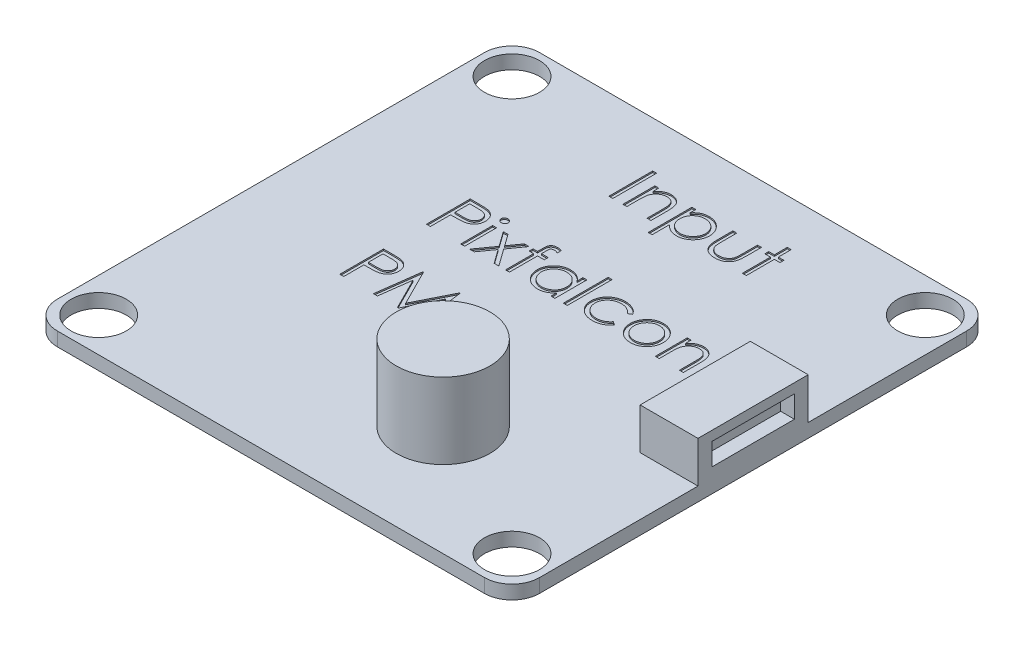
from build123d import *

# Parameters (mm, degrees)
SKETCH1_R           = 2
BOSS_EXTRUDE1_DEPTH = 1
SKETCH2_W           = 4.2
SKETCH2_H           = 8
BOSS_EXTRUDE2_DEPTH = 3
SKETCH3_W           = 6
SKETCH3_H           = 1.6
CUT_EXTRUDE1_DEPTH  = 1
SKETCH4_R           = 3.4
BOSS_EXTRUDE3_DEPTH = 5.5
SKETCH5_W           = 0.284935898
SKETCH5_H           = 2.320192307
SKETCH5_W_2         = 0.284935897
SKETCH5_H_2         = 3.256410256
SKETCH5_H_3         = 3.175
CUT_EXTRUDE2_DEPTH  = 0.1


with BuildPart() as part:
    # Sketch1 → Boss-Extrude1 (new body)
    with BuildSketch(Plane(origin=(0, 0, 0), x_dir=(1, 0, 0), z_dir=(0, 1, 0))):
        with BuildLine():
            Line((-15.5, 17.5), (15.5, 17.5))
            ThreePointArc((15.5, 17.5), (16.914213562, 16.914213562), (17.5, 15.5))
            Line((17.5, 15.5), (17.5, -15.5))
            ThreePointArc((17.5, -15.5), (16.914213562, -16.914213562), (15.5, -17.5))
            Line((15.5, -17.5), (-15.5, -17.5))
            ThreePointArc((-15.5, -17.5), (-16.914213562, -16.914213562), (-17.5, -15.5))
            Line((-17.5, -15.5), (-17.5, 15.5))
            ThreePointArc((-17.5, 15.5), (-16.914213562, 16.914213562), (-15.5, 17.5))
        make_face()
        with Locations((15, 15)):
            Circle(SKETCH1_R, mode=Mode.SUBTRACT)
        with Locations((15, -15)):
            Circle(SKETCH1_R, mode=Mode.SUBTRACT)
        with Locations((-15, -15)):
            Circle(SKETCH1_R, mode=Mode.SUBTRACT)
        with Locations((-15, 15)):
            Circle(SKETCH1_R, mode=Mode.SUBTRACT)
    extrude(amount=BOSS_EXTRUDE1_DEPTH)

    # Sketch2 → Boss-Extrude2 (add)
    with BuildSketch(Plane(origin=(0, 1, 0), x_dir=(1, 0, 0), z_dir=(0, 1, 0))):
        with Locations((15.4, 0)):
            Rectangle(SKETCH2_W, SKETCH2_H)
    extrude(amount=BOSS_EXTRUDE2_DEPTH)

    # Sketch3 → Cut-Extrude1 (cut)
    with BuildSketch(Plane(origin=(17.5, 0, 0), x_dir=(0, 0, -1), z_dir=(1, 0, 0))):
        with Locations((0, 2.5)):
            Rectangle(SKETCH3_W, SKETCH3_H)
    extrude(amount=-CUT_EXTRUDE1_DEPTH, mode=Mode.SUBTRACT)

    # Sketch4 → Boss-Extrude3 (add)
    with BuildSketch(Plane(origin=(0, 1, 0), x_dir=(1, 0, 0), z_dir=(0, 1, 0))):
        with Locations((4.5, -9.5)):
            Circle(SKETCH4_R)
    extrude(amount=BOSS_EXTRUDE3_DEPTH)

    # Sketch5 → Cut-Extrude2 (cut)
    with BuildSketch(Plane(origin=(0, 1, 0), x_dir=(1, 0, 0), z_dir=(0, 1, 0))):
        with BuildLine():
            Line((-8.813380042, 5.781823516), (-8.190718784, 5.781823516))
            add(Edge.make_bspline(
                [(-8.190718784, 5.781823516), (-8.147891748, 5.781776438), (-8.065833244, 5.781686236), (-7.948163158, 5.778951431), (-7.841292901, 5.775298646), (-7.745452913, 5.770235072), (-7.66034831, 5.764251022), (-7.586364188, 5.7558581), (-7.522919019, 5.747094832), (-7.484903883, 5.738185414), (-7.467566741, 5.734122194)],
                knots=[0, 0, 0, 0, 0.000128477, 0.000246168, 0.000353087, 0.00044926, 0.000534089, 0.000608961, 0.000672646, 0.000726041, 0.000726041, 0.000726041, 0.000726041], degree=3))
            add(Edge.make_bspline(
                [(-7.467566741, 5.734122194), (-7.445619749, 5.728115139), (-7.40224292, 5.716242579), (-7.339739831, 5.692462987), (-7.280273128, 5.664267023), (-7.223638786, 5.632132449), (-7.170532754, 5.594680544), (-7.120162702, 5.553429477), (-7.072973149, 5.507426839), (-7.029229457, 5.457188597), (-6.989056819, 5.403558121), (-6.95446775, 5.345734812), (-6.925505194, 5.284691987), (-6.900664655, 5.220472104), (-6.882786271, 5.152535882), (-6.869318012, 5.081355365), (-6.860769436, 5.006938182), (-6.859950683, 4.956083873), (-6.859533888, 4.930195912)],
                knots=[0, 0, 0, 0, 6.8232e-05, 0.000134856, 0.000200292, 0.000265532, 0.000329934, 0.000395001, 0.000460668, 0.00052738, 0.000594672, 0.000661426, 0.000729131, 0.00079717, 0.00086768, 0.00093953, 0.001014402, 0.001092038, 0.001092038, 0.001092038, 0.001092038], degree=3))
            add(Edge.make_bspline(
                [(-6.859533888, 4.930195912), (-6.859916181, 4.904090357), (-6.860664162, 4.853013076), (-6.869641506, 4.77828919), (-6.881733894, 4.706880364), (-6.900327649, 4.638944934), (-6.924680509, 4.574886342), (-6.9532483, 4.513725653), (-6.987704789, 4.45650338), (-7.027296884, 4.40301178), (-7.071340116, 4.353200645), (-7.119648139, 4.307430939), (-7.172025925, 4.265970575), (-7.228307017, 4.228726606), (-7.289040094, 4.196562695), (-7.353304048, 4.167754283), (-7.421657458, 4.143559821), (-7.468958167, 4.130832551), (-7.493007446, 4.124361577)],
                knots=[0, 0, 0, 0, 7.8272e-05, 0.000153144, 0.000225504, 0.0002954, 0.000364034, 0.000430891, 0.000497646, 0.000564048, 0.000630282, 0.000696867, 0.000763418, 0.000830451, 0.000899029, 0.000969354, 0.001041572, 0.001116269, 0.001116269, 0.001116269, 0.001116269], degree=3))
            add(Edge.make_bspline(
                [(-7.493007446, 4.124361577), (-7.51289867, 4.120131587), (-7.556491445, 4.110861318), (-7.6282852, 4.100512218), (-7.711874229, 4.091678823), (-7.80714444, 4.085055648), (-7.914010318, 4.079385671), (-8.032529673, 4.0748789), (-8.162935157, 4.072402532), (-8.2538955, 4.072274813), (-8.301385851, 4.072208131)],
                knots=[0, 0, 0, 0, 6.0995e-05, 0.000133673, 0.000217466, 0.000313125, 0.000420129, 0.000538512, 0.000668921, 0.00081139, 0.00081139, 0.00081139, 0.00081139], degree=3))
            Line((-8.301385851, 4.072208131), (-8.528444145, 4.072208131))
            Line((-8.528444145, 4.072208131), (-8.528444145, 2.606823516))
            Line((-8.528444145, 2.606823516), (-8.813380042, 2.606823516))
            Line((-8.813380042, 2.606823516), (-8.813380042, 5.781823516))
        make_face()
        with BuildLine():
            Line((-8.528444145, 5.45618249), (-8.528444145, 4.397849157))
            Line((-8.528444145, 4.397849157), (-7.972564738, 4.390852963))
            add(Edge.make_bspline(
                [(-7.972564738, 4.390852963), (-7.945423091, 4.390838935), (-7.893026701, 4.390811855), (-7.817338127, 4.394427022), (-7.747116845, 4.398600362), (-7.682578551, 4.404710807), (-7.623694154, 4.413347948), (-7.570365467, 4.422067167), (-7.523006003, 4.434681318), (-7.467580298, 4.451665816), (-7.405818976, 4.48063326), (-7.338629129, 4.522679232), (-7.281687239, 4.576273874), (-7.232412785, 4.636533407), (-7.193309595, 4.703570475), (-7.164683802, 4.775297296), (-7.147864324, 4.850978274), (-7.145608991, 4.902765371), (-7.144469786, 4.928923876)],
                knots=[0, 0, 0, 0, 8.1413e-05, 0.000157166, 0.000227269, 0.000292454, 0.000351549, 0.000405819, 0.000454411, 0.000498462, 0.000579576, 0.00065826, 0.000735229, 0.000813005, 0.000891109, 0.000967051, 0.001043901, 0.00112234, 0.00112234, 0.00112234, 0.00112234], degree=3))
            add(Edge.make_bspline(
                [(-7.144469786, 4.928923876), (-7.145615186, 4.954449528), (-7.147892101, 5.005191364), (-7.164815634, 5.079557811), (-7.19325394, 5.150528771), (-7.23267528, 5.216725784), (-7.280519019, 5.276768485), (-7.33612628, 5.328926593), (-7.399366167, 5.370856281), (-7.458192777, 5.397919329), (-7.510445281, 5.414443186), (-7.555831417, 5.426004577), (-7.607076528, 5.435235306), (-7.6641973, 5.442709712), (-7.726750999, 5.449108209), (-7.795275042, 5.453449774), (-7.869509847, 5.455991095), (-7.92104515, 5.456117147), (-7.94776005, 5.45618249)],
                knots=[0, 0, 0, 0, 7.6536e-05, 0.000152145, 0.000227496, 0.000305051, 0.000382429, 0.000457133, 0.000532809, 0.00060908, 0.000650514, 0.0006971, 0.000749494, 0.000806611, 0.000869897, 0.000938097, 0.001012554, 0.001092695, 0.001092695, 0.001092695, 0.001092695], degree=3))
            Line((-7.94776005, 5.45618249), (-8.528444145, 5.45618249))
        make_face(mode=Mode.SUBTRACT)
        with BuildLine():
            add(Edge.make_bspline(
                [(-6.189171308, 5.9039389), (-6.1714899, 5.903118705), (-6.136866308, 5.901512605), (-6.086798129, 5.887758979), (-6.04120784, 5.864445693), (-6.000769468, 5.833167697), (-5.966069542, 5.796383559), (-5.941775612, 5.753511109), (-5.92616151, 5.70719363), (-5.924275963, 5.674885656), (-5.92331594, 5.658436096)],
                knots=[0, 0, 0, 0, 5.2977e-05, 0.000103739, 0.000154369, 0.000205635, 0.000256504, 0.000304942, 0.000352409, 0.000401646, 0.000401646, 0.000401646, 0.000401646], degree=3))
            add(Edge.make_bspline(
                [(-5.92331594, 5.658436096), (-5.924297613, 5.642413546), (-5.926238266, 5.610738862), (-5.941763551, 5.565224355), (-5.966276581, 5.522947612), (-6.000747217, 5.486234896), (-6.041213736, 5.454974191), (-6.086796563, 5.431656321), (-6.13686672, 5.41790391), (-6.171490039, 5.416297643), (-6.189171308, 5.415477362)],
                knots=[0, 0, 0, 0, 4.7972e-05, 9.4835e-05, 0.000142722, 0.000193592, 0.000244857, 0.000295488, 0.00034625, 0.000399227, 0.000399227, 0.000399227, 0.000399227], degree=3))
            add(Edge.make_bspline(
                [(-6.189171308, 5.415477362), (-6.206650386, 5.416266322), (-6.240671128, 5.417801931), (-6.289989621, 5.431926161), (-6.335191179, 5.45498217), (-6.375708418, 5.48603021), (-6.409481522, 5.523173081), (-6.434063574, 5.565198555), (-6.449553004, 5.61074543), (-6.451498488, 5.642415753), (-6.452482606, 5.658436096)],
                knots=[0, 0, 0, 0, 5.2343e-05, 0.000101879, 0.000152509, 0.000203775, 0.000254217, 0.000302105, 0.000348968, 0.00039694, 0.00039694, 0.00039694, 0.00039694], degree=3))
            add(Edge.make_bspline(
                [(-6.452482606, 5.658436096), (-6.451520049, 5.674883367), (-6.449629526, 5.707186844), (-6.434051964, 5.753537338), (-6.409686281, 5.796156272), (-6.375686055, 5.833372261), (-6.335197131, 5.864437762), (-6.289988083, 5.887489153), (-6.240671535, 5.901614582), (-6.206650524, 5.903150025), (-6.189171308, 5.9039389)],
                knots=[0, 0, 0, 0, 4.9237e-05, 9.6705e-05, 0.000145142, 0.000195584, 0.00024685, 0.00029748, 0.000347016, 0.000399359, 0.000399359, 0.000399359, 0.000399359], degree=3))
        make_face()
        with Locations((-6.187899273, 3.76691967)):
            Rectangle(SKETCH5_W, SKETCH5_H)
        Polygon((-5.556969786, 4.927015823), (-5.21797239, 4.927015823), (-4.620751837, 4.090016625), (-4.023531284, 4.927015823), (-3.684533888, 4.927015823), (-4.45093513, 3.852782049), (-3.562418504, 2.606823516), (-3.901415899, 2.606823516), (-4.620751837, 3.614911456), (-5.340087774, 2.606823516), (-5.67908517, 2.606823516), (-4.789932526, 3.852782049), align=None)
        with BuildLine():
            Line((-2.259854401, 5.844153243), (-2.259854401, 5.547769029))
            add(Edge.make_bspline(
                [(-2.259854401, 5.547769029), (-2.286831722, 5.558610177), (-2.338035238, 5.579186902), (-2.413546151, 5.601561241), (-2.482968736, 5.616017234), (-2.527558336, 5.618045555), (-2.548606404, 5.619003003)],
                knots=[0, 0, 0, 0, 8.7172e-05, 0.000165453, 0.000236054, 0.000299177, 0.000299177, 0.000299177, 0.000299177], degree=3))
            add(Edge.make_bspline(
                [(-2.548606404, 5.619003003), (-2.562824747, 5.618412144), (-2.590346717, 5.617268439), (-2.629901163, 5.611437075), (-2.665542089, 5.599550963), (-2.697206474, 5.584102976), (-2.723468677, 5.56473168), (-2.745953323, 5.545268691), (-2.762251532, 5.523329278), (-2.771100663, 5.502900048), (-2.776498164, 5.483985219), (-2.778122066, 5.464613848), (-2.782099809, 5.440824856), (-2.78320907, 5.411647769), (-2.785737611, 5.37799031), (-2.785513872, 5.339140197), (-2.787585717, 5.295708789), (-2.787275552, 5.264956148), (-2.787113015, 5.248840743)],
                knots=[0, 0, 0, 0, 4.2689e-05, 8.2632e-05, 0.000119438, 0.000154993, 0.00018782, 0.000217084, 0.000243925, 0.000268981, 0.000283485, 0.000302734, 0.000327111, 0.000355796, 0.000390193, 0.00042836, 0.000472263, 0.000520601, 0.000520601, 0.000520601, 0.000520601], degree=3))
            Line((-2.787113015, 5.248840743), (-2.787113015, 4.927015823))
            Line((-2.787113015, 4.927015823), (-2.300559529, 4.927015823))
            Line((-2.300559529, 4.927015823), (-2.300559529, 4.642079926))
            Line((-2.300559529, 4.642079926), (-2.787749032, 4.642079926))
            Line((-2.787749032, 4.642079926), (-2.789021068, 2.606823516))
            Line((-2.789021068, 2.606823516), (-3.073956965, 2.606823516))
            Line((-3.073956965, 2.606823516), (-3.073956965, 4.642079926))
            Line((-3.073956965, 4.642079926), (-3.399597991, 4.642079926))
            Line((-3.399597991, 4.642079926), (-3.399597991, 4.927015823))
            Line((-3.399597991, 4.927015823), (-3.073956965, 4.927015823))
            Line((-3.073956965, 4.927015823), (-3.073956965, 5.297814101))
            add(Edge.make_bspline(
                [(-3.073956965, 5.297814101), (-3.073934092, 5.318384091), (-3.073890212, 5.357845626), (-3.070816948, 5.414641332), (-3.068190116, 5.467095475), (-3.062958053, 5.514800877), (-3.056914934, 5.558204165), (-3.048264275, 5.596660564), (-3.040089674, 5.63120616), (-3.025259166, 5.670306427), (-3.003104724, 5.714620378), (-2.967245189, 5.761450629), (-2.92425296, 5.803455831), (-2.872901124, 5.838841073), (-2.815102031, 5.868246542), (-2.750802677, 5.889330223), (-2.680703033, 5.901250484), (-2.632182257, 5.903023231), (-2.607120026, 5.9039389)],
                knots=[0, 0, 0, 0, 6.1697e-05, 0.00011836, 0.00017061, 0.000219214, 0.0002623, 0.000301968, 0.000337448, 0.000368639, 0.000427236, 0.000485368, 0.000544739, 0.000606848, 0.0006717, 0.000738675, 0.000809047, 0.000884229, 0.000884229, 0.000884229, 0.000884229], degree=3))
            add(Edge.make_bspline(
                [(-2.607120026, 5.9039389), (-2.581650395, 5.903070419), (-2.528178257, 5.901247089), (-2.444542768, 5.889968213), (-2.354194498, 5.870490922), (-2.292204056, 5.853184555), (-2.259854401, 5.844153243)],
                knots=[0, 0, 0, 0, 7.6417e-05, 0.000160434, 0.000252742, 0.000353487, 0.000353487, 0.000353487, 0.000353487], degree=3))
        make_face()
        with BuildLine():
            Line((0.508094317, 4.927015823), (0.508094317, 2.606823516))
            Line((0.508094317, 2.606823516), (0.223158419, 2.606823516))
            Line((0.223158419, 2.606823516), (0.223158419, 3.008150639))
            add(Edge.make_bspline(
                [(0.223158419, 3.008150639), (0.191028517, 2.971829007), (0.128326607, 2.900946887), (0.023605021, 2.808343773), (-0.087400397, 2.731800581), (-0.204150881, 2.669978872), (-0.326541002, 2.623540364), (-0.454299453, 2.590532919), (-0.587478348, 2.569311369), (-0.678421556, 2.567192263), (-0.724507847, 2.566118388)],
                knots=[0, 0, 0, 0, 0.000145381, 0.000283713, 0.000418146, 0.000549018, 0.000679067, 0.000809885, 0.000944361, 0.001082524, 0.001082524, 0.001082524, 0.001082524], degree=3))
            add(Edge.make_bspline(
                [(-0.724507847, 2.566118388), (-0.765481633, 2.567230882), (-0.846283755, 2.569424771), (-0.965145846, 2.586444861), (-1.07952953, 2.613777639), (-1.189542892, 2.651787732), (-1.294474053, 2.702207477), (-1.395221426, 2.762569895), (-1.491263082, 2.834452648), (-1.581135121, 2.916628931), (-1.663895579, 3.005887241), (-1.73652259, 3.101087844), (-1.79707717, 3.201819077), (-1.847713957, 3.306805581), (-1.886717784, 3.416855544), (-1.913908152, 3.531588403), (-1.930908415, 3.650868503), (-1.933101397, 3.732093641), (-1.934213375, 3.773279846)],
                knots=[0, 0, 0, 0, 0.000122885, 0.000242334, 0.00035942, 0.00047528, 0.000590784, 0.00070804, 0.000827103, 0.000950019, 0.001072896, 0.001191833, 0.001308545, 0.001424896, 0.001540967, 0.001658053, 0.001778133, 0.001901653, 0.001901653, 0.001901653, 0.001901653], degree=3))
            add(Edge.make_bspline(
                [(-1.934213375, 3.773279846), (-1.933076751, 3.813614777), (-1.930829707, 3.89335476), (-1.91409, 4.010629007), (-1.885940443, 4.123584858), (-1.846436324, 4.231858657), (-1.795779693, 4.335581416), (-1.734159214, 4.434826496), (-1.661570437, 4.529867307), (-1.577884325, 4.618469062), (-1.487229212, 4.700312048), (-1.39024772, 4.771440254), (-1.289352315, 4.83286911), (-1.182978012, 4.881540477), (-1.072699282, 4.920918736), (-0.95753437, 4.948162929), (-0.837962438, 4.964216927), (-0.756781777, 4.966541721), (-0.7156036, 4.967720952)],
                knots=[0, 0, 0, 0, 0.000120979, 0.000239169, 0.000354553, 0.000469642, 0.000584275, 0.000700235, 0.000819557, 0.000942401, 0.001065363, 0.001185447, 0.001302704, 0.001419089, 0.001535759, 0.001653464, 0.001773457, 0.001896977, 0.001896977, 0.001896977, 0.001896977], degree=3))
            add(Edge.make_bspline(
                [(-0.7156036, 4.967720952), (-0.66825087, 4.966416706), (-0.575394403, 4.963859141), (-0.439569709, 4.942575095), (-0.311077933, 4.906617343), (-0.188927199, 4.85770647), (-0.073556148, 4.792710837), (0.033942988, 4.710723301), (0.134695248, 4.612260938), (0.193097369, 4.536632035), (0.223158419, 4.497703924)],
                knots=[0, 0, 0, 0, 0.000142004, 0.000278464, 0.000411172, 0.000541562, 0.000672282, 0.000807119, 0.000946093, 0.001093501, 0.001093501, 0.001093501, 0.001093501], degree=3))
            Line((0.223158419, 4.497703924), (0.223158419, 4.927015823))
            Line((0.223158419, 4.927015823), (0.508094317, 4.927015823))
        make_face()
        with BuildLine():
            add(Edge.make_bspline(
                [(-0.711787494, 4.682785054), (-0.753438358, 4.681303111), (-0.835650538, 4.678377992), (-0.956340454, 4.655542036), (-1.071831908, 4.617546725), (-1.181547275, 4.565583858), (-1.283753443, 4.500243504), (-1.375096988, 4.421211963), (-1.456325009, 4.330645529), (-1.524640363, 4.2289529), (-1.580330314, 4.119934203), (-1.619488979, 4.005974892), (-1.645314653, 3.889130376), (-1.647953097, 3.80987994), (-1.649277478, 3.770099758)],
                knots=[0, 0, 0, 0, 0.000124893, 0.000246519, 0.000366995, 0.00048876, 0.000609786, 0.000729752, 0.00085002, 0.00097368, 0.001096273, 0.001216155, 0.001334406, 0.001453586, 0.001453586, 0.001453586, 0.001453586], degree=3))
            add(Edge.make_bspline(
                [(-1.649277478, 3.770099758), (-1.647585753, 3.730557303), (-1.644208935, 3.651627388), (-1.619942234, 3.534623579), (-1.579229777, 3.420637412), (-1.523674477, 3.310636368), (-1.454108753, 3.208506505), (-1.373474047, 3.11621368), (-1.280990578, 3.036848125), (-1.178549196, 2.970411183), (-1.069140537, 2.916742325), (-0.954084042, 2.879399209), (-0.835542571, 2.855289365), (-0.754940811, 2.852473161), (-0.714331565, 2.851054285)],
                knots=[0, 0, 0, 0, 0.000118588, 0.000236711, 0.000356804, 0.000480819, 0.000605362, 0.000726581, 0.000847444, 0.000969696, 0.001092011, 0.001211883, 0.001331754, 0.001453472, 0.001453472, 0.001453472, 0.001453472], degree=3))
            add(Edge.make_bspline(
                [(-0.714331565, 2.851054285), (-0.673105094, 2.852560109), (-0.591109734, 2.855555045), (-0.470061763, 2.878488764), (-0.352591332, 2.916379031), (-0.240298632, 2.96890181), (-0.135690428, 3.033995983), (-0.041803067, 3.110202416), (0.037586418, 3.198833161), (0.104889714, 3.296238944), (0.157663128, 3.403020541), (0.196104267, 3.516716556), (0.218831739, 3.637330949), (0.221696251, 3.719757512), (0.223158419, 3.761831529)],
                knots=[0, 0, 0, 0, 0.000123623, 0.000245874, 0.000368165, 0.000493079, 0.000616791, 0.00073699, 0.000854515, 0.000972537, 0.001091147, 0.001210617, 0.001331618, 0.00145778, 0.00145778, 0.00145778, 0.00145778], degree=3))
            add(Edge.make_bspline(
                [(0.223158419, 3.761831529), (0.222287874, 3.793887989), (0.220574365, 3.856985248), (0.207483777, 3.949629496), (0.18666038, 4.038287947), (0.157317782, 4.123053815), (0.118772117, 4.203458436), (0.072283073, 4.280079133), (0.017033129, 4.352517404), (-0.046088317, 4.419775761), (-0.115181036, 4.481122623), (-0.188291798, 4.535881613), (-0.266286804, 4.580865714), (-0.347854402, 4.61809601), (-0.433136113, 4.647722525), (-0.522825889, 4.667487075), (-0.615970399, 4.681058224), (-0.679512178, 4.682203383), (-0.711787494, 4.682785054)],
                knots=[0, 0, 0, 0, 9.6142e-05, 0.000189237, 0.000280101, 0.000369007, 0.000457768, 0.000547103, 0.000637419, 0.000730567, 0.000823369, 0.000914322, 0.0010041, 0.001092899, 0.001183007, 0.001274346, 0.001368072, 0.001464822, 0.001464822, 0.001464822, 0.001464822], degree=3))
        make_face(mode=Mode.SUBTRACT)
        with Locations((1.261139189, 4.235028644)):
            Rectangle(SKETCH5_W_2, SKETCH5_H_2)
        with BuildLine():
            Line((4.334376368, 4.42392588), (4.095869758, 4.275733772))
            add(Edge.make_bspline(
                [(4.095869758, 4.275733772), (4.069716951, 4.308235244), (4.018239592, 4.372208872), (3.928850428, 4.454767883), (3.833590073, 4.525676557), (3.730830701, 4.583464959), (3.62071644, 4.628115847), (3.503681539, 4.659711819), (3.379742688, 4.679400668), (3.294774972, 4.681638441), (3.251238347, 4.682785054)],
                knots=[0, 0, 0, 0, 0.000125005, 0.00024605, 0.000363844, 0.000480601, 0.000598709, 0.000719366, 0.000843592, 0.000974131, 0.000974131, 0.000974131, 0.000974131], degree=3))
            add(Edge.make_bspline(
                [(3.251238347, 4.682785054), (3.216441294, 4.681826347), (3.147909442, 4.6799382), (3.047301717, 4.668135824), (2.951469011, 4.646689145), (2.859810654, 4.618430777), (2.77297856, 4.5805573), (2.690745227, 4.534465593), (2.612381247, 4.48089877), (2.540157488, 4.418840633), (2.474091175, 4.351350413), (2.416851446, 4.279002418), (2.367015799, 4.203963659), (2.327912539, 4.124360293), (2.29591292, 4.042013445), (2.274861109, 3.955368733), (2.260832421, 3.865536183), (2.259227388, 3.804287404), (2.25841483, 3.773279846)],
                knots=[0, 0, 0, 0, 0.000104402, 0.000205617, 0.000303301, 0.000398648, 0.000492936, 0.000586896, 0.000681104, 0.000777202, 0.000872105, 0.000963985, 0.0010536, 0.001141775, 0.001229541, 0.001318085, 0.001408752, 0.001501717, 0.001501717, 0.001501717, 0.001501717], degree=3))
            add(Edge.make_bspline(
                [(2.25841483, 3.773279846), (2.260028866, 3.732667776), (2.26323519, 3.651990848), (2.288364371, 3.532902856), (2.329498226, 3.417764937), (2.385793562, 3.307394555), (2.456983534, 3.205255572), (2.540597217, 3.113649152), (2.636680956, 3.034350327), (2.744388142, 2.968607393), (2.861189809, 2.91575601), (2.985822262, 2.878102929), (3.117267062, 2.855376848), (3.207261754, 2.852513957), (3.2531464, 2.851054285)],
                knots=[0, 0, 0, 0, 0.00012176, 0.00024188, 0.000363385, 0.000487688, 0.000612427, 0.000735772, 0.000858657, 0.000984866, 0.001113248, 0.001242216, 0.001374486, 0.001512078, 0.001512078, 0.001512078, 0.001512078], degree=3))
            add(Edge.make_bspline(
                [(3.2531464, 2.851054285), (3.295197175, 2.852233115), (3.377838105, 2.854549828), (3.498639857, 2.874079673), (3.613647347, 2.906050683), (3.722856489, 2.950634623), (3.826067726, 3.008263155), (3.922614191, 3.079346117), (4.014416993, 3.161838605), (4.06838925, 3.22562705), (4.095869758, 3.258105567)],
                knots=[0, 0, 0, 0, 0.000126092, 0.000247804, 0.000366009, 0.000483528, 0.00060084, 0.00071966, 0.000842576, 0.00097008, 0.00097008, 0.00097008, 0.00097008], degree=3))
            Line((4.095869758, 3.258105567), (4.334376368, 3.10164523))
            add(Edge.make_bspline(
                [(4.334376368, 3.10164523), (4.320236095, 3.080880071), (4.292002483, 3.039418674), (4.244805995, 2.980958654), (4.19389729, 2.926238271), (4.139474981, 2.875330874), (4.082249679, 2.827018243), (4.020266504, 2.783610029), (3.955524071, 2.742666297), (3.887262335, 2.70582462), (3.816187059, 2.672708171), (3.742398254, 2.644231894), (3.666216566, 2.619766156), (3.587552425, 2.60031942), (3.506250746, 2.584797445), (3.422521792, 2.574498015), (3.3363944, 2.566809725), (3.278181091, 2.566350831), (3.248694277, 2.566118388)],
                knots=[0, 0, 0, 0, 7.5343e-05, 0.000150436, 0.000225141, 0.000299381, 0.000373893, 0.000449603, 0.000526189, 0.000603598, 0.000682135, 0.00076127, 0.000840722, 0.000922015, 0.001004219, 0.001088867, 0.001175014, 0.001263441, 0.001263441, 0.001263441, 0.001263441], degree=3))
            add(Edge.make_bspline(
                [(3.248694277, 2.566118388), (3.203690118, 2.566926906), (3.11548164, 2.568511607), (2.986374794, 2.585936438), (2.862990967, 2.612205133), (2.745372314, 2.649909377), (2.633500523, 2.698445852), (2.527479909, 2.75773391), (2.427661521, 2.828265891), (2.335032453, 2.908786403), (2.249959284, 2.996090413), (2.176910526, 3.090297125), (2.113550888, 3.187942932), (2.062671474, 3.291184431), (2.022170333, 3.398649447), (1.994498092, 3.511198879), (1.976600402, 3.627904853), (1.97452905, 3.70749111), (1.973478932, 3.747839141)],
                knots=[0, 0, 0, 0, 0.000134932, 0.000264467, 0.000390091, 0.000512988, 0.000634334, 0.000755353, 0.000876757, 0.001000312, 0.001123109, 0.001241815, 0.001357376, 0.001471719, 0.001586432, 0.001701199, 0.001818851, 0.001939829, 0.001939829, 0.001939829, 0.001939829], degree=3))
            add(Edge.make_bspline(
                [(1.973478932, 3.747839141), (1.973878997, 3.775215292), (1.974674792, 3.829670976), (1.983802397, 3.910492929), (1.995593869, 3.990238538), (2.015574359, 4.067896969), (2.038652647, 4.144646054), (2.068112593, 4.219560724), (2.102670559, 4.292989106), (2.141906254, 4.364742046), (2.186073901, 4.433639129), (2.234951877, 4.498729953), (2.286699239, 4.560796454), (2.343736855, 4.617695866), (2.403644255, 4.671703697), (2.468116328, 4.721377138), (2.536783279, 4.76686218), (2.608613864, 4.808999887), (2.683566281, 4.846518803), (2.761187475, 4.87884324), (2.841009723, 4.906468077), (2.923160711, 4.92833831), (3.007095168, 4.946678402), (3.093474524, 4.958215305), (3.181968326, 4.966367138), (3.241890575, 4.967265928), (3.272226929, 4.967720952)],
                knots=[0, 0, 0, 0, 8.2086e-05, 0.000163282, 0.000243795, 0.000323701, 0.000403569, 0.00048412, 0.000564924, 0.000646901, 0.000729292, 0.000810194, 0.000890978, 0.000971482, 0.00105166, 0.001132824, 0.001215379, 0.00129861, 0.001382518, 0.00146662, 0.001550694, 0.001635707, 0.001721529, 0.001808238, 0.001896973, 0.001987959, 0.001987959, 0.001987959, 0.001987959], degree=3))
            add(Edge.make_bspline(
                [(3.272226929, 4.967720952), (3.31021817, 4.966884665), (3.386010754, 4.965216271), (3.49844268, 4.951174922), (3.609218606, 4.930005459), (3.716394907, 4.898642963), (3.818672103, 4.860666647), (3.914407832, 4.818019399), (4.001348498, 4.768494294), (4.081111382, 4.714319619), (4.153845659, 4.653213655), (4.220297949, 4.584445915), (4.281830945, 4.508374295), (4.316716676, 4.452307667), (4.334376368, 4.42392588)],
                knots=[0, 0, 0, 0, 0.000113934, 0.000227299, 0.000339435, 0.00045196, 0.000561834, 0.000666582, 0.000765982, 0.000861599, 0.000955493, 0.001050396, 0.001148136, 0.001248336, 0.001248336, 0.001248336, 0.001248336], degree=3))
        make_face()
        with BuildLine():
            add(Edge.make_bspline(
                [(6.024911224, 4.967720952), (6.068446164, 4.96679395), (6.153807543, 4.964976327), (6.278818982, 4.945549894), (6.398149213, 4.915843357), (6.512255259, 4.874775582), (6.619675755, 4.819728384), (6.721975384, 4.754042813), (6.81887367, 4.676225746), (6.876951704, 4.616029498), (6.906431657, 4.585474357)],
                knots=[0, 0, 0, 0, 0.000130509, 0.000255897, 0.000378531, 0.000499054, 0.000618803, 0.000739829, 0.000863296, 0.000990571, 0.000990571, 0.000990571, 0.000990571], degree=3))
            add(Edge.make_bspline(
                [(6.906431657, 4.585474357), (6.931815286, 4.55625167), (6.982091303, 4.498371835), (7.046558062, 4.404522815), (7.102094763, 4.307331438), (7.146601878, 4.205507077), (7.18169472, 4.099938626), (7.206610031, 3.99026323), (7.221429964, 3.876723101), (7.22342837, 3.799612476), (7.224440471, 3.760559493)],
                knots=[0, 0, 0, 0, 0.000116043, 0.000229841, 0.000340916, 0.00045141, 0.000562633, 0.000674184, 0.000788337, 0.000905475, 0.000905475, 0.000905475, 0.000905475], degree=3))
            add(Edge.make_bspline(
                [(7.224440471, 3.760559493), (7.223550258, 3.721280155), (7.221791155, 3.643662351), (7.205150874, 3.529344784), (7.179269104, 3.418496623), (7.142228793, 3.311581951), (7.094732508, 3.208273958), (7.036774528, 3.109023867), (6.967948132, 3.01363586), (6.889930221, 2.922919907), (6.80370459, 2.839311983), (6.710163513, 2.766442767), (6.611145211, 2.704011813), (6.505333026, 2.653723065), (6.393693234, 2.614072122), (6.275985037, 2.586222822), (6.152391294, 2.569384723), (6.068002315, 2.567222481), (6.024911224, 2.566118388)],
                knots=[0, 0, 0, 0, 0.000117773, 0.000232725, 0.000345804, 0.000458844, 0.000571541, 0.000686407, 0.000803078, 0.000923941, 0.00104494, 0.001162753, 0.001279048, 0.001395399, 0.001513481, 0.001633808, 0.001757668, 0.001886907, 0.001886907, 0.001886907, 0.001886907], degree=3))
            add(Edge.make_bspline(
                [(6.024911224, 2.566118388), (5.981609014, 2.567226187), (5.896799449, 2.569395868), (5.772769451, 2.586157403), (5.654850296, 2.614059287), (5.543064353, 2.65385337), (5.436797242, 2.70401342), (5.337205206, 2.766254025), (5.243588139, 2.839333594), (5.157344268, 2.922914051), (5.079331247, 3.013637369), (5.01050359, 3.109023475), (4.952545937, 3.20827406), (4.905049566, 3.311581924), (4.868009279, 3.418496631), (4.842127502, 3.529344782), (4.825487223, 3.643662352), (4.82372812, 3.721280155), (4.822837907, 3.760559493)],
                knots=[0, 0, 0, 0, 0.000129874, 0.000254364, 0.000374691, 0.000492773, 0.000609698, 0.000726534, 0.000844346, 0.000965345, 0.001086209, 0.001202879, 0.001317745, 0.001430442, 0.001543482, 0.001656561, 0.001771513, 0.001889286, 0.001889286, 0.001889286, 0.001889286], degree=3))
            add(Edge.make_bspline(
                [(4.822837907, 3.760559493), (4.82385691, 3.799400217), (4.82587436, 3.876298175), (4.840679394, 3.989624866), (4.865497513, 4.09911464), (4.900632422, 4.204275608), (4.945549774, 4.305653753), (5.000306085, 4.403085278), (5.065430445, 4.496509926), (5.115506501, 4.554314956), (5.140846721, 4.583566304)],
                knots=[0, 0, 0, 0, 0.000116502, 0.000230655, 0.000342206, 0.000452826, 0.000562738, 0.000674367, 0.000787643, 0.000903686, 0.000903686, 0.000903686, 0.000903686], degree=3))
            add(Edge.make_bspline(
                [(5.140846721, 4.583566304), (5.170282228, 4.614386428), (5.228172333, 4.674999623), (5.325552965, 4.752589842), (5.427600931, 4.81964228), (5.536208543, 4.873595704), (5.65022085, 4.916084931), (5.770162591, 4.945626505), (5.895598237, 4.964906335), (5.981377322, 4.966773396), (6.024911224, 4.967720952)],
                knots=[0, 0, 0, 0, 0.000127724, 0.000251192, 0.000372563, 0.000493448, 0.000614191, 0.000736825, 0.000863471, 0.00099398, 0.00099398, 0.00099398, 0.00099398], degree=3))
        make_face()
        with BuildLine():
            add(Edge.make_bspline(
                [(6.023639189, 4.682785054), (5.992852927, 4.681910032), (5.932075146, 4.680182575), (5.842613094, 4.667043605), (5.756488812, 4.64622694), (5.673538903, 4.616650404), (5.594043097, 4.578460688), (5.517925282, 4.531553818), (5.444961568, 4.476551065), (5.376579268, 4.413538499), (5.313821028, 4.344705411), (5.258958863, 4.2713644), (5.212308945, 4.194705071), (5.173446801, 4.114647708), (5.144502423, 4.030381018), (5.123481181, 3.942859303), (5.110354606, 3.851904247), (5.108643391, 3.790072466), (5.107773804, 3.75865144)],
                knots=[0, 0, 0, 0, 9.233e-05, 0.000182276, 0.000270667, 0.000357773, 0.00044596, 0.000534752, 0.000625576, 0.000719657, 0.000813309, 0.000904642, 0.000993977, 0.001082163, 0.001171069, 0.001260696, 0.001351902, 0.001446138, 0.001446138, 0.001446138, 0.001446138], degree=3))
            add(Edge.make_bspline(
                [(5.107773804, 3.75865144), (5.109231423, 3.718054959), (5.112124523, 3.637478534), (5.135651487, 3.518814158), (5.175009041, 3.404893478), (5.228156074, 3.296384328), (5.294746001, 3.195988761), (5.373202125, 3.106479629), (5.462682425, 3.029203929), (5.56212025, 2.965086304), (5.669484524, 2.914141383), (5.783109901, 2.878038027), (5.901619674, 2.854568706), (5.982610051, 2.852236011), (6.023639189, 2.851054285)],
                knots=[0, 0, 0, 0, 0.000121719, 0.000241589, 0.000361264, 0.000482436, 0.000603094, 0.00072162, 0.000838414, 0.000956612, 0.001075534, 0.001193802, 0.001313553, 0.001436504, 0.001436504, 0.001436504, 0.001436504], degree=3))
            add(Edge.make_bspline(
                [(6.023639189, 2.851054285), (6.064665966, 2.852242896), (6.145651685, 2.854589182), (6.263996796, 2.877919826), (6.377311613, 2.914299575), (6.484564372, 2.965029008), (6.583956934, 3.029447413), (6.674080779, 3.10604327), (6.751867019, 3.196225835), (6.818391075, 3.296517307), (6.872408478, 3.404725255), (6.911581811, 3.518835184), (6.935165335, 3.637473179), (6.938050801, 3.718053165), (6.939504573, 3.75865144)],
                knots=[0, 0, 0, 0, 0.000122951, 0.000242701, 0.000360364, 0.000479286, 0.000597484, 0.00071476, 0.000832868, 0.000953525, 0.00107498, 0.001194654, 0.001314525, 0.001436243, 0.001436243, 0.001436243, 0.001436243], degree=3))
            add(Edge.make_bspline(
                [(6.939504573, 3.75865144), (6.938635286, 3.790072653), (6.93692466, 3.851904804), (6.923793799, 3.942857173), (6.902788417, 4.030388835), (6.873785593, 4.114618867), (6.835092309, 4.194912353), (6.787542789, 4.271139319), (6.732904645, 4.344959472), (6.669389114, 4.413315989), (6.601078192, 4.476575629), (6.528084908, 4.531575147), (6.452079963, 4.578254537), (6.372815106, 4.616977055), (6.289854562, 4.645957857), (6.203850952, 4.667163801), (6.114770603, 4.680127051), (6.054210614, 4.681893386), (6.023639189, 4.682785054)],
                knots=[0, 0, 0, 0, 9.4236e-05, 0.000185442, 0.000275068, 0.000363974, 0.000452161, 0.000541828, 0.00063316, 0.000727242, 0.000821323, 0.000912146, 0.001000939, 0.001088552, 0.001176258, 0.001264031, 0.001353977, 0.001445672, 0.001445672, 0.001445672, 0.001445672], degree=3))
        make_face(mode=Mode.SUBTRACT)
        with BuildLine():
            Line((7.794312266, 4.927015823), (8.079248163, 4.927015823))
            Line((8.079248163, 4.927015823), (8.079248163, 4.508516224))
            add(Edge.make_bspline(
                [(8.079248163, 4.508516224), (8.109671589, 4.546473551), (8.168709309, 4.620131069), (8.267029383, 4.716941876), (8.370937064, 4.796720758), (8.479796024, 4.860314914), (8.59375404, 4.908254354), (8.712116471, 4.942876306), (8.835591954, 4.963636114), (8.919561122, 4.96634868), (8.962040631, 4.967720952)],
                knots=[0, 0, 0, 0, 0.000145848, 0.000283023, 0.000412777, 0.000537898, 0.000660162, 0.000782735, 0.000907163, 0.001034558, 0.001034558, 0.001034558, 0.001034558], degree=3))
            add(Edge.make_bspline(
                [(8.962040631, 4.967720952), (9.004976278, 4.96613781), (9.089011695, 4.96303922), (9.211365365, 4.938531222), (9.325641229, 4.896670883), (9.431431826, 4.839328505), (9.526797227, 4.768021204), (9.610549056, 4.684947074), (9.679821431, 4.589392198), (9.726264753, 4.500743335), (9.756858733, 4.422104214), (9.776119497, 4.354751805), (9.792476173, 4.279714625), (9.806656401, 4.197219427), (9.816251353, 4.106688211), (9.823819003, 4.008492091), (9.829242533, 3.902662872), (9.829457713, 3.829468575), (9.829568676, 3.791724357)],
                knots=[0, 0, 0, 0, 0.000128741, 0.000251978, 0.000372501, 0.000492599, 0.000611662, 0.000728592, 0.000845121, 0.000964321, 0.001027748, 0.001097989, 0.001174219, 0.001258077, 0.001348963, 0.001447206, 0.001553543, 0.001666761, 0.001666761, 0.001666761, 0.001666761], degree=3))
            Line((9.829568676, 3.791724357), (9.829568676, 2.606823516))
            Line((9.829568676, 2.606823516), (9.544632778, 2.606823516))
            Line((9.544632778, 2.606823516), (9.544632778, 3.698229766))
            add(Edge.make_bspline(
                [(9.544632778, 3.698229766), (9.544457511, 3.729818698), (9.544122255, 3.790242949), (9.543064847, 3.876756277), (9.540515951, 3.955211959), (9.536934267, 4.025422428), (9.531691861, 4.087320266), (9.526228474, 4.141031538), (9.519547387, 4.186488052), (9.513593888, 4.213852091), (9.510923844, 4.226124397)],
                knots=[0, 0, 0, 0, 9.4769e-05, 0.000181277, 0.000259548, 0.000330249, 0.000392152, 0.000445883, 0.000492208, 0.000529878, 0.000529878, 0.000529878, 0.000529878], degree=3))
            add(Edge.make_bspline(
                [(9.510923844, 4.226124397), (9.501284969, 4.262148115), (9.482733117, 4.331482626), (9.436891575, 4.425530075), (9.379002997, 4.505538431), (9.308338519, 4.571013028), (9.225580715, 4.621968001), (9.130959235, 4.657322946), (9.025387183, 4.679435705), (8.951133564, 4.68163746), (8.912431256, 4.682785054)],
                knots=[0, 0, 0, 0, 0.000111666, 0.000214922, 0.000311858, 0.000406371, 0.000502038, 0.000601493, 0.000708018, 0.000823984, 0.000823984, 0.000823984, 0.000823984], degree=3))
            add(Edge.make_bspline(
                [(8.912431256, 4.682785054), (8.889509857, 4.68235325), (8.844149002, 4.681498721), (8.776884384, 4.672925043), (8.711638884, 4.658902015), (8.647757695, 4.63997118), (8.586518482, 4.613970407), (8.525953732, 4.584461621), (8.468344024, 4.547678601), (8.412460943, 4.506684251), (8.360470039, 4.461255256), (8.312093617, 4.413317736), (8.268969842, 4.362267724), (8.229900401, 4.308927772), (8.196174405, 4.252565319), (8.166734818, 4.193724126), (8.141756009, 4.132326748), (8.129343852, 4.089713657), (8.123133379, 4.068392025)],
                knots=[0, 0, 0, 0, 6.8737e-05, 0.000136029, 0.000203016, 0.000268809, 0.000335543, 0.000402385, 0.000470679, 0.000540262, 0.000610145, 0.000677605, 0.000744384, 0.000810411, 0.000875747, 0.000941168, 0.001007661, 0.001074249, 0.001074249, 0.001074249, 0.001074249], degree=3))
            add(Edge.make_bspline(
                [(8.123133379, 4.068392025), (8.119559555, 4.052739091), (8.111779527, 4.018663472), (8.1033765, 3.962743177), (8.095749628, 3.898054843), (8.089366101, 3.824673955), (8.085460473, 3.742343597), (8.081201985, 3.651415373), (8.079651622, 3.551526709), (8.079386415, 3.481983602), (8.079248163, 3.445730767)],
                knots=[0, 0, 0, 0, 4.8153e-05, 0.000104826, 0.000169516, 0.000243568, 0.000325735, 0.000416765, 0.000516638, 0.000625399, 0.000625399, 0.000625399, 0.000625399], degree=3))
            Line((8.079248163, 3.445730767), (8.079248163, 2.606823516))
            Line((8.079248163, 2.606823516), (7.794312266, 2.606823516))
            Line((7.794312266, 2.606823516), (7.794312266, 4.927015823))
        make_face()
        with BuildLine():
            Line((-8.813380042, -0.509843151), (-8.190718784, -0.509843151))
            add(Edge.make_bspline(
                [(-8.190718784, -0.509843151), (-8.147891748, -0.509890228), (-8.065833244, -0.50998043), (-7.948163158, -0.512715236), (-7.841292901, -0.516368021), (-7.745452913, -0.521431595), (-7.66034831, -0.527415645), (-7.586364188, -0.535808566), (-7.522919019, -0.544571834), (-7.484903883, -0.553481253), (-7.467566741, -0.557544473)],
                knots=[0, 0, 0, 0, 0.000128477, 0.000246168, 0.000353087, 0.00044926, 0.000534089, 0.000608961, 0.000672646, 0.000726041, 0.000726041, 0.000726041, 0.000726041], degree=3))
            add(Edge.make_bspline(
                [(-7.467566741, -0.557544473), (-7.445619749, -0.563551528), (-7.40224292, -0.575424088), (-7.339739831, -0.59920368), (-7.280273128, -0.627399644), (-7.223638786, -0.659534218), (-7.170532754, -0.696986123), (-7.120162702, -0.73823719), (-7.072973149, -0.784239827), (-7.029229457, -0.83447807), (-6.989056819, -0.888108546), (-6.95446775, -0.945931855), (-6.925505194, -1.00697468), (-6.900664655, -1.071194562), (-6.882786271, -1.139130784), (-6.869318012, -1.210311302), (-6.860769436, -1.284728485), (-6.859950683, -1.335582794), (-6.859533888, -1.361470755)],
                knots=[0, 0, 0, 0, 6.8232e-05, 0.000134856, 0.000200292, 0.000265532, 0.000329934, 0.000395001, 0.000460668, 0.00052738, 0.000594672, 0.000661426, 0.000729131, 0.00079717, 0.00086768, 0.00093953, 0.001014402, 0.001092038, 0.001092038, 0.001092038, 0.001092038], degree=3))
            add(Edge.make_bspline(
                [(-6.859533888, -1.361470755), (-6.859916181, -1.38757631), (-6.860664162, -1.438653591), (-6.869641506, -1.513377477), (-6.881733894, -1.584786302), (-6.900327649, -1.652721732), (-6.924680509, -1.716780324), (-6.9532483, -1.777941013), (-6.987704789, -1.835163287), (-7.027296884, -1.888654887), (-7.071340116, -1.938466021), (-7.119648139, -1.984235728), (-7.172025925, -2.025696092), (-7.228307017, -2.062940061), (-7.289040094, -2.095103971), (-7.353304048, -2.123912384), (-7.421657458, -2.148106846), (-7.468958167, -2.160834116), (-7.493007446, -2.16730509)],
                knots=[0, 0, 0, 0, 7.8272e-05, 0.000153144, 0.000225504, 0.0002954, 0.000364034, 0.000430891, 0.000497646, 0.000564048, 0.000630282, 0.000696867, 0.000763418, 0.000830451, 0.000899029, 0.000969354, 0.001041572, 0.001116269, 0.001116269, 0.001116269, 0.001116269], degree=3))
            add(Edge.make_bspline(
                [(-7.493007446, -2.16730509), (-7.51289867, -2.17153508), (-7.556491445, -2.180805349), (-7.6282852, -2.191154449), (-7.711874229, -2.199987844), (-7.80714444, -2.206611019), (-7.914010318, -2.212280996), (-8.032529673, -2.216787767), (-8.162935157, -2.219264134), (-8.2538955, -2.219391853), (-8.301385851, -2.219458536)],
                knots=[0, 0, 0, 0, 6.0995e-05, 0.000133673, 0.000217466, 0.000313125, 0.000420129, 0.000538512, 0.000668921, 0.00081139, 0.00081139, 0.00081139, 0.00081139], degree=3))
            Line((-8.301385851, -2.219458536), (-8.528444145, -2.219458536))
            Line((-8.528444145, -2.219458536), (-8.528444145, -3.684843151))
            Line((-8.528444145, -3.684843151), (-8.813380042, -3.684843151))
            Line((-8.813380042, -3.684843151), (-8.813380042, -0.509843151))
        make_face()
        with BuildLine():
            Line((-8.528444145, -0.835484177), (-8.528444145, -1.89381751))
            Line((-8.528444145, -1.89381751), (-7.972564738, -1.900813704))
            add(Edge.make_bspline(
                [(-7.972564738, -1.900813704), (-7.945423091, -1.900827732), (-7.893026701, -1.900854812), (-7.817338127, -1.897239645), (-7.747116845, -1.893066304), (-7.682578551, -1.886955859), (-7.623694154, -1.878318719), (-7.570365467, -1.869599499), (-7.523006003, -1.856985349), (-7.467580298, -1.840000851), (-7.405818976, -1.811033406), (-7.338629129, -1.768987435), (-7.281687239, -1.715392792), (-7.232412785, -1.65513326), (-7.193309595, -1.588096192), (-7.164683802, -1.516369371), (-7.147864324, -1.440688393), (-7.145608991, -1.388901296), (-7.144469786, -1.36274279)],
                knots=[0, 0, 0, 0, 8.1413e-05, 0.000157166, 0.000227269, 0.000292454, 0.000351549, 0.000405819, 0.000454411, 0.000498462, 0.000579576, 0.00065826, 0.000735229, 0.000813005, 0.000891109, 0.000967051, 0.001043901, 0.00112234, 0.00112234, 0.00112234, 0.00112234], degree=3))
            add(Edge.make_bspline(
                [(-7.144469786, -1.36274279), (-7.145615186, -1.337217139), (-7.147892101, -1.286475303), (-7.164815634, -1.212108856), (-7.19325394, -1.141137895), (-7.23267528, -1.074940882), (-7.280519019, -1.014898182), (-7.33612628, -0.962740073), (-7.399366167, -0.920810386), (-7.458192777, -0.893747338), (-7.510445281, -0.877223481), (-7.555831417, -0.86566209), (-7.607076528, -0.856431361), (-7.6641973, -0.848956955), (-7.726750999, -0.842558458), (-7.795275042, -0.838216893), (-7.869509847, -0.835675572), (-7.92104515, -0.83554952), (-7.94776005, -0.835484177)],
                knots=[0, 0, 0, 0, 7.6536e-05, 0.000152145, 0.000227496, 0.000305051, 0.000382429, 0.000457133, 0.000532809, 0.00060908, 0.000650514, 0.0006971, 0.000749494, 0.000806611, 0.000869897, 0.000938097, 0.001012554, 0.001092695, 0.001092695, 0.001092695, 0.001092695], degree=3))
            Line((-7.94776005, -0.835484177), (-8.528444145, -0.835484177))
        make_face(mode=Mode.SUBTRACT)
        Polygon((-6.37107235, -3.684843151), (-5.951936733, -0.509843151), (-5.911231605, -0.509843151), (-4.600399273, -3.114971356), (-3.292747029, -0.509843151), (-3.251405883, -0.509843151), (-2.829726196, -3.684843151), (-3.115934129, -3.684843151), (-3.419950555, -1.40026783), (-4.566054321, -3.684843151), (-4.630292101, -3.684843151), (-5.780847991, -1.395179689), (-6.084228399, -3.684843151), align=None)
        with Locations((-3.810682041, 12.574585632)):
            Rectangle(SKETCH5_W, SKETCH5_H_3)
        with BuildLine():
            Line((-2.935521785, 13.30727794), (-2.650585887, 13.30727794))
            Line((-2.650585887, 13.30727794), (-2.650585887, 12.888778341))
            add(Edge.make_bspline(
                [(-2.650585887, 12.888778341), (-2.620162461, 12.926735668), (-2.561124741, 13.000393185), (-2.462804667, 13.097203992), (-2.358896986, 13.176982875), (-2.250038026, 13.240577031), (-2.13608001, 13.28851647), (-2.017717579, 13.323138422), (-1.894242096, 13.343898231), (-1.810272928, 13.346610797), (-1.767793419, 13.347983068)],
                knots=[0, 0, 0, 0, 0.000145848, 0.000283023, 0.000412777, 0.000537898, 0.000660162, 0.000782735, 0.000907163, 0.001034558, 0.001034558, 0.001034558, 0.001034558], degree=3))
            add(Edge.make_bspline(
                [(-1.767793419, 13.347983068), (-1.724857773, 13.346399927), (-1.640822355, 13.343301337), (-1.518468685, 13.318793338), (-1.404192821, 13.276933), (-1.298402224, 13.219590622), (-1.203036823, 13.148283321), (-1.119284994, 13.06520919), (-1.050012619, 12.969654315), (-1.003569297, 12.881005452), (-0.972975317, 12.802366331), (-0.953714554, 12.735013922), (-0.937357877, 12.659976742), (-0.923177649, 12.577481543), (-0.913582697, 12.486950328), (-0.906015047, 12.388754207), (-0.900591517, 12.282924989), (-0.900376337, 12.209730691), (-0.900265374, 12.171986474)],
                knots=[0, 0, 0, 0, 0.000128741, 0.000251978, 0.000372501, 0.000492599, 0.000611662, 0.000728592, 0.000845121, 0.000964321, 0.001027748, 0.001097989, 0.001174219, 0.001258077, 0.001348963, 0.001447206, 0.001553543, 0.001666761, 0.001666761, 0.001666761, 0.001666761], degree=3))
            Line((-0.900265374, 12.171986474), (-0.900265374, 10.987085632))
            Line((-0.900265374, 10.987085632), (-1.185201272, 10.987085632))
            Line((-1.185201272, 10.987085632), (-1.185201272, 12.078491882))
            add(Edge.make_bspline(
                [(-1.185201272, 12.078491882), (-1.185376539, 12.110080815), (-1.185711795, 12.170505066), (-1.186769204, 12.257018394), (-1.1893181, 12.335474076), (-1.192899783, 12.405684545), (-1.19814219, 12.467582382), (-1.203605577, 12.521293655), (-1.210286663, 12.566750168), (-1.216240163, 12.594114207), (-1.218910206, 12.606386514)],
                knots=[0, 0, 0, 0, 9.4769e-05, 0.000181277, 0.000259548, 0.000330249, 0.000392152, 0.000445883, 0.000492208, 0.000529878, 0.000529878, 0.000529878, 0.000529878], degree=3))
            add(Edge.make_bspline(
                [(-1.218910206, 12.606386514), (-1.228549081, 12.642410232), (-1.247100933, 12.711744743), (-1.292942475, 12.805792191), (-1.350831053, 12.885800547), (-1.421495531, 12.951275145), (-1.504253335, 13.002230118), (-1.598874815, 13.037585063), (-1.704446867, 13.059697821), (-1.778700486, 13.061899577), (-1.817402794, 13.063047171)],
                knots=[0, 0, 0, 0, 0.000111666, 0.000214922, 0.000311858, 0.000406371, 0.000502038, 0.000601493, 0.000708018, 0.000823984, 0.000823984, 0.000823984, 0.000823984], degree=3))
            add(Edge.make_bspline(
                [(-1.817402794, 13.063047171), (-1.840324193, 13.062615367), (-1.885685049, 13.061760837), (-1.952949666, 13.05318716), (-2.018195166, 13.039164132), (-2.082076356, 13.020233297), (-2.143315568, 12.994232524), (-2.203880318, 12.964723738), (-2.261490026, 12.927940717), (-2.317373107, 12.886946368), (-2.369364012, 12.841517373), (-2.417740433, 12.793579853), (-2.460864208, 12.742529841), (-2.499933649, 12.689189888), (-2.533659646, 12.632827435), (-2.563099233, 12.573986243), (-2.588078041, 12.512588865), (-2.600490198, 12.469975774), (-2.606700671, 12.448654142)],
                knots=[0, 0, 0, 0, 6.8737e-05, 0.000136029, 0.000203016, 0.000268809, 0.000335543, 0.000402385, 0.000470679, 0.000540262, 0.000610145, 0.000677605, 0.000744384, 0.000810411, 0.000875747, 0.000941168, 0.001007661, 0.001074249, 0.001074249, 0.001074249, 0.001074249], degree=3))
            add(Edge.make_bspline(
                [(-2.606700671, 12.448654142), (-2.610274495, 12.433001208), (-2.618054523, 12.398925589), (-2.62645755, 12.343005294), (-2.634084422, 12.27831696), (-2.640467949, 12.204936072), (-2.644373577, 12.122605714), (-2.648632065, 12.03167749), (-2.650182428, 11.931788825), (-2.650447635, 11.862245718), (-2.650585887, 11.825992884)],
                knots=[0, 0, 0, 0, 4.8153e-05, 0.000104826, 0.000169516, 0.000243568, 0.000325735, 0.000416765, 0.000516638, 0.000625399, 0.000625399, 0.000625399, 0.000625399], degree=3))
            Line((-2.650585887, 11.825992884), (-2.650585887, 10.987085632))
            Line((-2.650585887, 10.987085632), (-2.935521785, 10.987085632))
            Line((-2.935521785, 10.987085632), (-2.935521785, 13.30727794))
        make_face()
        with BuildLine():
            Line((-0.248983323, 13.30727794), (0.035952574, 13.30727794))
            Line((0.035952574, 13.30727794), (0.035952574, 12.877966041))
            add(Edge.make_bspline(
                [(0.035952574, 12.877966041), (0.066212578, 12.9169167), (0.125016839, 12.99260951), (0.226367288, 13.090571983), (0.33334375, 13.173190295), (0.448699132, 13.237944449), (0.570640622, 13.286767615), (0.698667796, 13.322853258), (0.833867247, 13.344118025), (0.926301886, 13.346677674), (0.973442558, 13.347983068)],
                knots=[0, 0, 0, 0, 0.000147809, 0.000287238, 0.000421569, 0.000552289, 0.000682679, 0.000814774, 0.000950605, 0.001091975, 0.001091975, 0.001091975, 0.001091975], degree=3))
            add(Edge.make_bspline(
                [(0.973442558, 13.347983068), (1.014619227, 13.346791827), (1.096007076, 13.344437277), (1.21580729, 13.328496006), (1.331173531, 13.301174957), (1.441453123, 13.261804126), (1.547827475, 13.21313095), (1.648721808, 13.151701925), (1.745707677, 13.080576309), (1.836345934, 12.998722858), (1.920094603, 12.910160073), (1.992526496, 12.81488984), (2.055003152, 12.716045208), (2.105504064, 12.612093811), (2.145063065, 12.503854223), (2.173197808, 12.390889138), (2.189941528, 12.273617392), (2.192188023, 12.193877067), (2.193324369, 12.153541963)],
                knots=[0, 0, 0, 0, 0.00012352, 0.000244144, 0.000361849, 0.000478519, 0.000594903, 0.00071216, 0.000832245, 0.000955207, 0.001078051, 0.001197373, 0.001313669, 0.001428302, 0.001543391, 0.001658775, 0.001776965, 0.001897944, 0.001897944, 0.001897944, 0.001897944], degree=3))
            add(Edge.make_bspline(
                [(2.193324369, 12.153541963), (2.192212679, 12.112355583), (2.190020265, 12.031130098), (2.173015867, 11.911852517), (2.145840702, 11.797110399), (2.106780779, 11.687094596), (2.056306, 11.581880855), (1.994888292, 11.481545053), (1.922419854, 11.386119336), (1.839596688, 11.296899206), (1.749741525, 11.214712686), (1.653695516, 11.142832437), (1.552949205, 11.082469904), (1.448018025, 11.032048219), (1.338003696, 10.994046023), (1.223419508, 10.966634161), (1.104327847, 10.949730012), (1.023318945, 10.947505568), (0.982346805, 10.946380504)],
                knots=[0, 0, 0, 0, 0.00012352, 0.0002436, 0.000360686, 0.000476757, 0.000593108, 0.000710151, 0.000829088, 0.000951964, 0.00107488, 0.001193943, 0.0013112, 0.001426703, 0.001542563, 0.001659649, 0.001779729, 0.001902613, 0.001902613, 0.001902613, 0.001902613], degree=3))
            add(Edge.make_bspline(
                [(0.982346805, 10.946380504), (0.936238936, 10.94755508), (0.845162378, 10.949875211), (0.711995919, 10.973387819), (0.583837632, 11.008527753), (0.462107384, 11.05996184), (0.345840869, 11.125507915), (0.235695759, 11.205436459), (0.13108699, 11.299580312), (0.068123332, 11.371001316), (0.035952574, 11.407493285)],
                knots=[0, 0, 0, 0, 0.000138193, 0.000272972, 0.000404455, 0.00053616, 0.0006683, 0.000804048, 0.000943651, 0.0010895, 0.0010895, 0.0010895, 0.0010895], degree=3))
            Line((0.035952574, 11.407493285), (0.035952574, 10.13227794))
            Line((0.035952574, 10.13227794), (-0.248983323, 10.13227794))
            Line((-0.248983323, 10.13227794), (-0.248983323, 13.30727794))
        make_face()
        with BuildLine():
            add(Edge.make_bspline(
                [(0.970898488, 13.063047171), (0.938622742, 13.062466365), (0.875080117, 13.061322909), (0.781941747, 13.047739398), (0.692229466, 13.028020161), (0.60684741, 12.998164366), (0.524977208, 12.961516871), (0.44724943, 12.915722475), (0.373718637, 12.861609584), (0.304569831, 12.800214751), (0.242100986, 12.732564855), (0.186798901, 12.660367343), (0.14034656, 12.583713645), (0.101791156, 12.50331778), (0.072451178, 12.418549557), (0.051627061, 12.329891753), (0.03853667, 12.237247328), (0.036823134, 12.174150093), (0.035952574, 12.142093645)],
                knots=[0, 0, 0, 0, 9.675e-05, 0.000190476, 0.000281815, 0.000371923, 0.000461301, 0.000550529, 0.000641994, 0.000734796, 0.000827511, 0.000917828, 0.001007163, 0.001095923, 0.001184829, 0.001275693, 0.001368789, 0.00146493, 0.00146493, 0.00146493, 0.00146493], degree=3))
            add(Edge.make_bspline(
                [(0.035952574, 12.142093645), (0.037395708, 12.100013), (0.040222929, 12.017573453), (0.063207542, 11.897119285), (0.100613817, 11.783135283), (0.153707722, 11.676581343), (0.220788735, 11.578625485), (0.301613492, 11.490913292), (0.395450663, 11.413996113), (0.500740187, 11.349206833), (0.613608834, 11.296603373), (0.731343197, 11.258944053), (0.852324196, 11.235746389), (0.934119743, 11.23280106), (0.975350611, 11.231316402)],
                knots=[0, 0, 0, 0, 0.000126163, 0.000247163, 0.000366431, 0.000485041, 0.000603063, 0.000721446, 0.000841645, 0.000965897, 0.001091387, 0.001214284, 0.00133591, 0.001459533, 0.001459533, 0.001459533, 0.001459533], degree=3))
            add(Edge.make_bspline(
                [(0.975350611, 11.231316402), (1.015750915, 11.232728258), (1.095938255, 11.235530538), (1.214010265, 11.259785894), (1.328755344, 11.296838167), (1.437775929, 11.350867193), (1.540122951, 11.417079603), (1.632544074, 11.496509061), (1.71328606, 11.588574938), (1.782105868, 11.691089794), (1.837560858, 11.801013178), (1.879226147, 11.914752009), (1.90327321, 12.031905357), (1.906681154, 12.110824711), (1.908388472, 12.150361874)],
                knots=[0, 0, 0, 0, 0.000121084, 0.00024033, 0.000360202, 0.000481946, 0.000604197, 0.000725061, 0.00084628, 0.000970466, 0.001094482, 0.001214788, 0.001332911, 0.001451499, 0.001451499, 0.001451499, 0.001451499], degree=3))
            add(Edge.make_bspline(
                [(1.908388472, 12.150361874), (1.90706882, 12.190144615), (1.904439799, 12.269400147), (1.878543558, 12.386206495), (1.839627149, 12.500404873), (1.782877152, 12.608827086), (1.715566001, 12.71112929), (1.634152653, 12.80143888), (1.542879389, 12.880515133), (1.440654219, 12.945843398), (1.330943976, 12.997809525), (1.21545116, 13.035803969), (1.094761606, 13.058640156), (1.012549377, 13.061565244), (0.970898488, 13.063047171)],
                knots=[0, 0, 0, 0, 0.00011918, 0.000237431, 0.000357313, 0.000480195, 0.000603499, 0.000723767, 0.000843733, 0.000964759, 0.001086524, 0.001207, 0.001328626, 0.001453519, 0.001453519, 0.001453519, 0.001453519], degree=3))
        make_face(mode=Mode.SUBTRACT)
        with BuildLine():
            Line((2.722491036, 13.30727794), (3.007426933, 13.30727794))
            Line((3.007426933, 13.30727794), (3.007426933, 12.231136113))
            add(Edge.make_bspline(
                [(3.007426933, 12.231136113), (3.007555661, 12.199546905), (3.007801912, 12.139118229), (3.009471908, 12.052163881), (3.013399922, 11.972864435), (3.018311034, 11.901174081), (3.024626686, 11.837104947), (3.032140878, 11.780880816), (3.040539589, 11.731864092), (3.048760765, 11.702342619), (3.052584185, 11.688613076)],
                knots=[0, 0, 0, 0, 9.4769e-05, 0.000181288, 0.000260882, 0.000332932, 0.000396851, 0.000453969, 0.000503119, 0.000545851, 0.000545851, 0.000545851, 0.000545851], degree=3))
            add(Edge.make_bspline(
                [(3.052584185, 11.688613076), (3.058717791, 11.671356615), (3.070857486, 11.637202449), (3.092877003, 11.587863852), (3.120116994, 11.542166274), (3.149925552, 11.49834758), (3.184305729, 11.457705777), (3.222822535, 11.420309499), (3.26418665, 11.384745788), (3.325650136, 11.342668155), (3.409705327, 11.297569248), (3.520061755, 11.258656613), (3.639717731, 11.235401262), (3.722417155, 11.232703188), (3.764923929, 11.231316402)],
                knots=[0, 0, 0, 0, 5.4937e-05, 0.000108733, 0.000161748, 0.000214322, 0.000267581, 0.000321101, 0.000375256, 0.000431008, 0.000544257, 0.000660328, 0.000780822, 0.000908255, 0.000908255, 0.000908255, 0.000908255], degree=3))
            add(Edge.make_bspline(
                [(3.764923929, 11.231316402), (3.807426753, 11.232732677), (3.889661855, 11.235472908), (4.008003149, 11.257955118), (4.116181218, 11.295515993), (4.213110295, 11.347955574), (4.298350736, 11.412128731), (4.36938403, 11.487429579), (4.427992039, 11.571475808), (4.453582014, 11.634181404), (4.466451372, 11.665716442)],
                knots=[0, 0, 0, 0, 0.000127432, 0.000246558, 0.000359807, 0.000469652, 0.000575869, 0.000678443, 0.000779171, 0.000881077, 0.000881077, 0.000881077, 0.000881077], degree=3))
            add(Edge.make_bspline(
                [(4.466451372, 11.665716442), (4.470256138, 11.67838587), (4.478667546, 11.706394881), (4.487704822, 11.753910796), (4.495845941, 11.810575115), (4.502797537, 11.876758633), (4.50775522, 11.952288393), (4.510427687, 12.037140791), (4.513446908, 12.131049453), (4.513492733, 12.196788063), (4.513516677, 12.231136113)],
                knots=[0, 0, 0, 0, 3.9663e-05, 8.7686e-05, 0.000144892, 0.000211407, 0.000287264, 0.000371914, 0.000466079, 0.000569116, 0.000569116, 0.000569116, 0.000569116], degree=3))
            Line((4.513516677, 12.231136113), (4.513516677, 13.30727794))
            Line((4.513516677, 13.30727794), (4.798452574, 13.30727794))
            Line((4.798452574, 13.30727794), (4.798452574, 12.177710632))
            add(Edge.make_bspline(
                [(4.798452574, 12.177710632), (4.798051894, 12.139331984), (4.79727452, 12.064872156), (4.792278572, 11.956664427), (4.783706424, 11.85582439), (4.770695559, 11.762298669), (4.755395983, 11.676158668), (4.735659936, 11.597293985), (4.712093963, 11.525947604), (4.685509674, 11.460867563), (4.654102694, 11.401860738), (4.620695326, 11.345857533), (4.582119283, 11.294247513), (4.541506284, 11.244461574), (4.496329068, 11.198976046), (4.447434196, 11.156747207), (4.395509865, 11.117129528), (4.339403807, 11.081668153), (4.279935093, 11.049721625), (4.217030308, 11.021404183), (4.149918974, 10.998995416), (4.07946696, 10.979663598), (4.005329096, 10.964501187), (3.927576854, 10.953809087), (3.846236424, 10.94725468), (3.790801414, 10.946676789), (3.762379858, 10.946380504)],
                knots=[0, 0, 0, 0, 0.000115135, 0.000223378, 0.000324896, 0.000418621, 0.000506569, 0.000587246, 0.000662266, 0.000731837, 0.000797836, 0.000862628, 0.000927252, 0.000990933, 0.001055247, 0.001119267, 0.00118465, 0.001250991, 0.001318148, 0.001387052, 0.00145765, 0.001530167, 0.001606131, 0.001684475, 0.001765499, 0.001850747, 0.001850747, 0.001850747, 0.001850747], degree=3))
            add(Edge.make_bspline(
                [(3.762379858, 10.946380504), (3.734170877, 10.946688667), (3.678737604, 10.947294236), (3.597392976, 10.953772876), (3.519425311, 10.964484573), (3.445111807, 10.979774663), (3.374377889, 10.998860105), (3.306937043, 11.021541884), (3.243578954, 11.049736321), (3.183542422, 11.081465963), (3.127297398, 11.117357319), (3.074584617, 11.156698327), (3.025474758, 11.199430255), (2.979956989, 11.245374644), (2.938670217, 11.295101436), (2.901099951, 11.348210623), (2.866667797, 11.404175975), (2.835504908, 11.464104701), (2.80873353, 11.529937881), (2.7850977, 11.602778819), (2.765765907, 11.683426102), (2.75003381, 11.77181078), (2.737377861, 11.867509854), (2.728591146, 11.971076916), (2.723678214, 12.082259694), (2.722895294, 12.159049237), (2.722491036, 12.198699214)],
                knots=[0, 0, 0, 0, 8.4612e-05, 0.00016627, 0.000244614, 0.000320578, 0.000393709, 0.000464306, 0.000533793, 0.00060151, 0.000667851, 0.000733743, 0.00079866, 0.000862973, 0.00092755, 0.000992318, 0.001057985, 0.001124549, 0.001194707, 0.001270936, 0.001354082, 0.001443281, 0.001540158, 0.001643577, 0.001754997, 0.001873947, 0.001873947, 0.001873947, 0.001873947], degree=3))
            Line((2.722491036, 12.198699214), (2.722491036, 13.30727794))
        make_face()
        Polygon((5.734670523, 14.243495889), (6.019606421, 14.243495889), (6.019606421, 13.30727794), (6.426657703, 13.30727794), (6.426657703, 13.022342043), (6.019606421, 13.022342043), (6.019606421, 10.987085632), (5.734670523, 10.987085632), (5.734670523, 13.022342043), (5.327619241, 13.022342043), (5.327619241, 13.30727794), (5.734670523, 13.30727794), align=None)
    extrude(amount=-CUT_EXTRUDE2_DEPTH, mode=Mode.SUBTRACT)


solid = part.part
